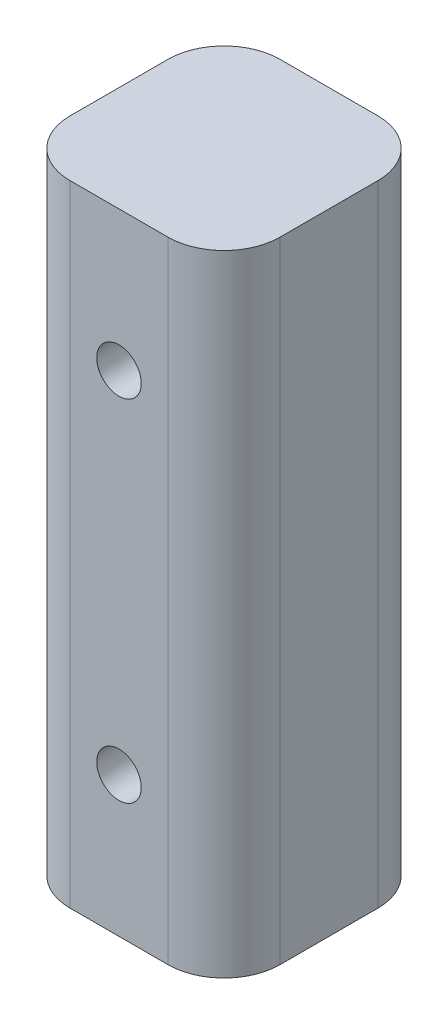
from build123d import *

# Parameters (mm, degrees)
BOSS_EXTRUDE1_DEPTH    = 57.15
F_10_32_TAPPED_HOLE1_D = 4.0386


with BuildPart() as part:
    # Sketch1 → Boss-Extrude1 (new body)
    with BuildSketch(Plane(origin=(0, 0, 0), x_dir=(1, 0, 0), z_dir=(0, 1, 0))):
        with BuildLine():
            Line((-4.445, 9.525), (4.445, 9.525))
            ThreePointArc((4.445, 9.525), (8.037102448, 8.037102448), (9.525, 4.445))
            Line((9.525, 4.445), (9.525, -4.445))
            ThreePointArc((9.525, -4.445), (8.037102448, -8.037102448), (4.445, -9.525))
            Line((4.445, -9.525), (-4.445, -9.525))
            ThreePointArc((-4.445, -9.525), (-8.037102448, -8.037102448), (-9.525, -4.445))
            Line((-9.525, -4.445), (-9.525, 4.445))
            ThreePointArc((-9.525, 4.445), (-8.037102448, 8.037102448), (-4.445, 9.525))
        make_face()
    extrude(amount=BOSS_EXTRUDE1_DEPTH)

    # #10-32 Tapped Hole1 (through all)
    with Locations(Plane.XY.offset(9.525)):
        with Locations((0, 44.45), (0, 12.7)):
            Hole(F_10_32_TAPPED_HOLE1_D / 2)


solid = part.part
